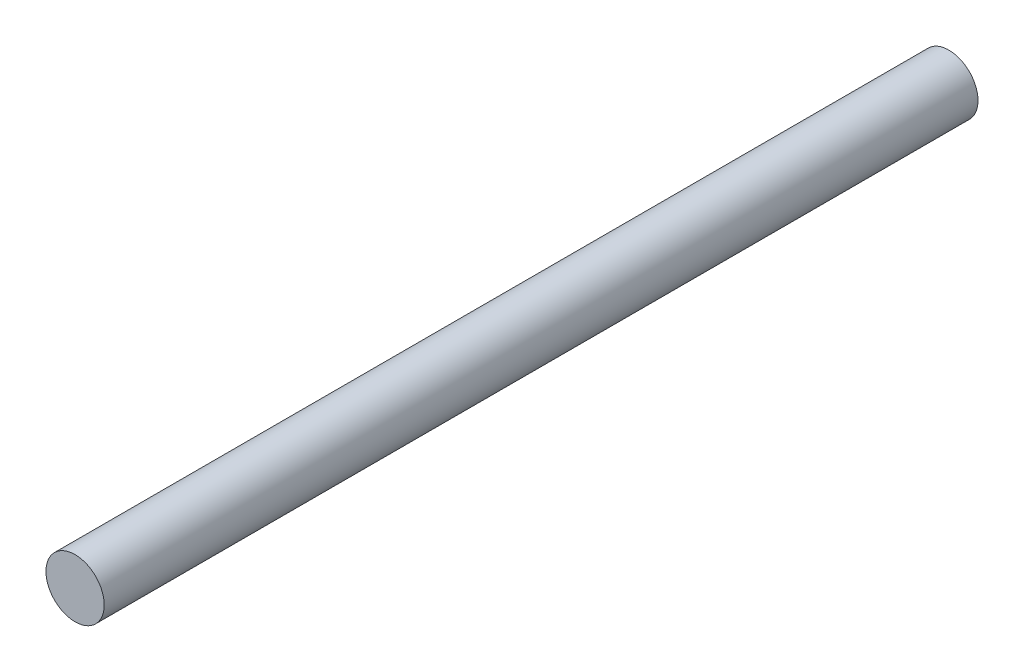
from build123d import *

# Parameters (mm, degrees)
ESQUISSE1_W = 4
ESQUISSE1_H = 120


with BuildPart() as part:
    # Esquisse1 → Révolution1 (revolve)
    with BuildSketch(Plane(origin=(0, 0, 0), x_dir=(1, 0, 0), z_dir=(0, 1, 0))):
        with Locations((2, -60)):
            Rectangle(ESQUISSE1_W, ESQUISSE1_H)
    revolve(axis=Axis((0, 0, 0), (0, 0, 1)))


solid = part.part
